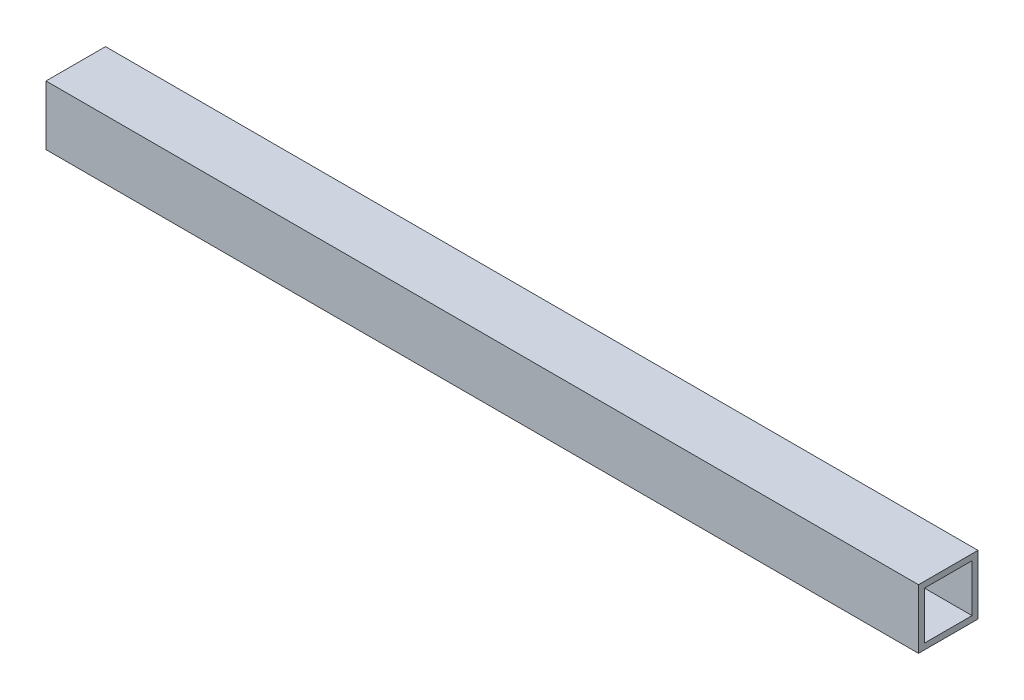
from build123d import *

# Parameters (mm, degrees)
SKETCH1_W           = 15
SKETCH1_H           = 15
SKETCH1_W_2         = 12
SKETCH1_H_2         = 12
BOSS_EXTRUDE1_DEPTH = 110


with BuildPart() as part:
    # Sketch1 → Boss-Extrude1 (new body, symmetric)
    with BuildSketch(Plane(origin=(0, 0, 0), x_dir=(0, 0, -1), z_dir=(1, 0, 0))):
        Rectangle(SKETCH1_W, SKETCH1_H)
        Rectangle(SKETCH1_W_2, SKETCH1_H_2, mode=Mode.SUBTRACT)
    extrude(amount=BOSS_EXTRUDE1_DEPTH, both=True)


solid = part.part
